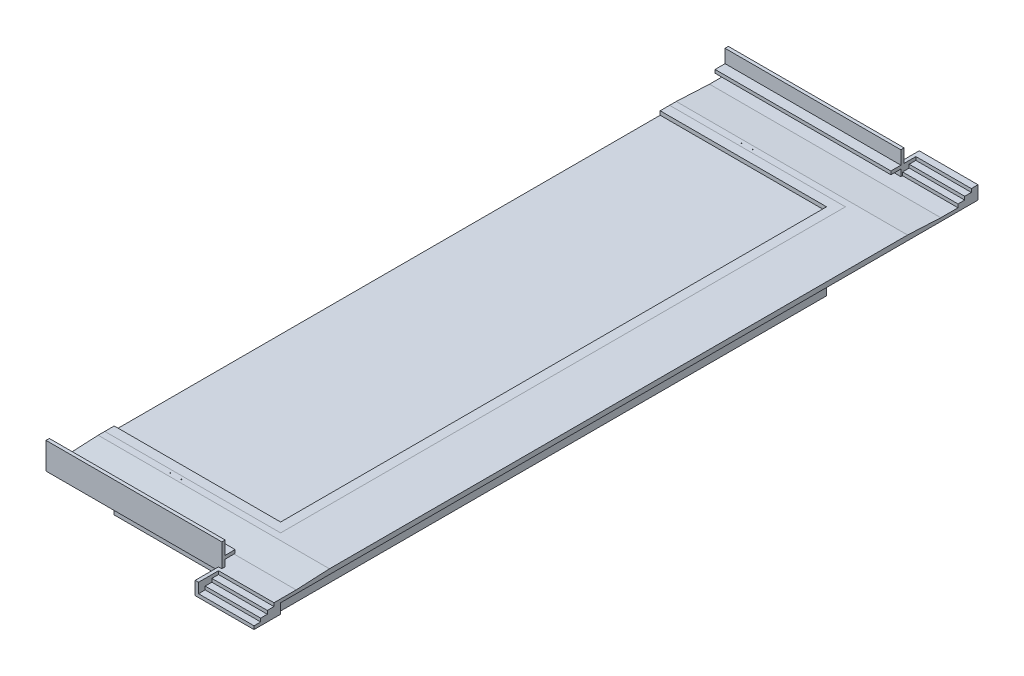
from build123d import *

# Parameters (mm, degrees)
SKETCH1_W                         = 7620
SKETCH1_H                         = 25000.0008
POOL_WATER_DEPTH                  = 3352.8
POOL_DECK_SUPPORT_DEPTH           = 101.6
POOL_DECK_SUPPORT_DEPTH_BACK      = 76.2
POOL_DECK_DEPTH                   = 152.4
SKETCH4_W                         = 8051.8
SKETCH4_H                         = 152.4
WALL_DEPTH                        = 1219.2
WALL_2_DEPTH                      = 1219.2
SKETCH7_W                         = 8051.8
SKETCH7_H                         = 152.4
NEAR_SIDE_BENCH_DEPTH             = 457.2
SKETCH8_W                         = 8051.8
SKETCH8_H                         = 152.4
FAR_SIDE_BENCH_DEPTH              = 457.2
STAIRS_DOWN_DEPTH                 = 2540
SLOPED_START                      = -8051.8
SLOPED_POOL_DECK_NEAR_SIDE_DEPTH  = 10591.8
SLOPED_POOL_DECK_FAR_SIDE_DEPTH   = 10591.8
SLOPED_POOL_DECK_LENGTH_DEPTH     = 25863.6008
DRAIN_CORRECTION_DEPTH            = 3455.4
STAIRS_UP_DEPTH                   = 2540
PERIMETER_DRAIN_DEPTH             = 228.6
SKETCH23_R                        = 3.175
FAR_SIDE_SWIM_LANE_EYELETS_DEPTH  = 152.4
SKETCH25_R                        = 3.175
NEAR_SIDE_SWIM_LANE_EYELETS_DEPTH = 152.4
SKETCH26_W                        = 838.2
SKETCH26_H                        = 609.6
FAR_SIDE_STAIRS_WALL_DEPTH        = 152.4
SKETCH27_W                        = 1066.8
SKETCH27_H                        = 609.6
NEAR_SIDE_STAIRS_WALL_DEPTH       = 152.4
SKETCH28_W                        = 101.6
SKETCH28_H                        = 127
FAR_SIDE_ELECTRICAL_BOX_DEPTH     = 76.2
SKETCH29_W                        = 25.4
SKETCH29_H                        = 25.4
FAR_SIDE_OUTLETS_DEPTH            = 6.35
FAR_SIDE_OUTLETS_2_DEPTH          = 6.35
SKETCH30_W                        = 101.6
SKETCH30_H                        = 127
NEAR_SIDE_ELECTRICAL_BOX_DEPTH    = 76.2
SKETCH31_W                        = 25.4
SKETCH31_H                        = 25.4
NEAR_SIDE_OUTLETS_DEPTH           = 6.35
NEAR_SIDE_OUTLETS_2_DEPTH         = 6.35
SKETCH32_R                        = 19.05
CUT_EXTRUDE4_DEPTH                = 152.4


with BuildPart() as part:
    # Sketch1 → Pool Water (new body)
    with BuildSketch(Plane(origin=(0, 0, 0), x_dir=(1, 0, 0), z_dir=(0, 1, 0))):
        with Locations((-3810, 12500.0004)):
            Rectangle(SKETCH1_W, SKETCH1_H)
    extrude(amount=-POOL_WATER_DEPTH)


with BuildPart() as body_2:
    # Sketch2 → Pool Deck Support (new body, two sides)
    with BuildSketch(Plane(origin=(0, 0, 0), x_dir=(1, 0, 0), z_dir=(0, 1, 0))) as pool_deck_support_sk:
        Polygon((-7620, 0), (-7620, -431.8), (431.8, -431.8), (431.8, 25431.8008), (-7620, 25431.8008), (-7620, 25000.0008), (0, 25000.0008), (0, 0), align=None)
    extrude(amount=POOL_DECK_SUPPORT_DEPTH)
    extrude(pool_deck_support_sk.sketch, amount=-POOL_DECK_SUPPORT_DEPTH_BACK)



with BuildPart() as body_3:
    # Sketch3 → Pool Deck (new body)
    with BuildSketch(Plane(origin=(0, 101.6, 0), x_dir=(1, 0, 0), z_dir=(0, 1, 0))):
        Polygon((-7620, -2971.8), (-7620, -431.8), (431.8, -431.8), (431.8, 25431.8008), (-7620, 25431.8008), (-7620, 27971.8008), (2971.8, 27971.8008), (2971.8, -2971.8), align=None)
    extrude(amount=-POOL_DECK_DEPTH)



with BuildPart() as body_4:
    # Sketch4 → Wall (new body)
    with BuildSketch(Plane(origin=(0, -50.8, 0), x_dir=(-1, 0, 0), z_dir=(0, -1, 0))):
        with Locations((3594.1, -3048)):
            Rectangle(SKETCH4_W, SKETCH4_H)
    extrude(amount=-WALL_DEPTH)

    # Sketch7 → Near Side Bench (add)
    with BuildSketch(Plane(origin=(0, 0, 2971.8), x_dir=(-1, 0, 0), z_dir=(0, 0, -1))):
        with Locations((3594.1, 482.6)):
            Rectangle(SKETCH7_W, SKETCH7_H)
    extrude(amount=NEAR_SIDE_BENCH_DEPTH)


with BuildPart() as body_5:
    # Sketch4 → Wall 2 (new body)
    with BuildSketch(Plane(origin=(0, -50.8, 0), x_dir=(-1, 0, 0), z_dir=(0, -1, 0))):
        with Locations((3594.1, 28048.0008)):
            Rectangle(SKETCH4_W, SKETCH4_H)
    extrude(amount=-WALL_2_DEPTH)

    # Sketch8 → Far Side Bench (add)
    with BuildSketch(Plane.XY.offset(-27971.8008)):
        with Locations((-3594.1, 482.6)):
            Rectangle(SKETCH8_W, SKETCH8_H)
    extrude(amount=FAR_SIDE_BENCH_DEPTH)


with BuildPart() as body_3_1:
    add(body_3.part)

    add(body_4.part)  # Stairs Down merges body 4
    # Sketch9 → Stairs Down (add)
    with BuildSketch(Plane(origin=(2971.8, 0, 0), x_dir=(0, 0, -1), z_dir=(1, 0, 0))):
        Polygon((-3276.6, -50.8), (-3581.4, -50.8), (-3581.4, -203.2), (-3886.2, -203.2), (-3886.2, -355.6), (-4191, -355.6), (-4191, -508), (-4160.29065508, -508), (-2971.8, -508), (-2971.8, -291.946336827), (-2971.8, 101.6), (-3276.6, 101.6), align=None)
    extrude(amount=-STAIRS_DOWN_DEPTH)


with BuildPart() as body_2_1:
    add(body_2.part)

    add(body_3_1.part)  # Sloped Pool Deck Near Side merges body 3
    # Sketch14 → Sloped Pool Deck Near Side (add)
    with BuildSketch(Plane(origin=(431.8, 0, 0), x_dir=(0, 0, -1), z_dir=(1, 0, 0)).offset(SLOPED_START)):
        Polygon((-431.8, 101.6), (-431.8, 177.8), (-736.6, 177.8), (-2260.6, 101.6), align=None)
    extrude(amount=SLOPED_POOL_DECK_NEAR_SIDE_DEPTH)

    # Sketch17 → Sloped Pool Deck Far Side (add)
    with BuildSketch(Plane.ZY.offset(7620)):
        Polygon((-25431.8008, 101.6), (-25431.8008, 177.8), (-25736.6008, 177.8), (-27260.6008, 101.6), align=None)
    extrude(amount=-SLOPED_POOL_DECK_FAR_SIDE_DEPTH)

    # Sketch15 → Sloped Pool Deck Length (add)
    with BuildSketch(Plane(origin=(0, 0, 431.8), x_dir=(-1, 0, 0), z_dir=(0, 0, -1))):
        Polygon((-431.8, 101.6), (-431.8, 177.8), (-1346.2, 177.8), (-2971.8, 177.8), (-2971.8, 101.6), (-2260.6, 101.6), (-1346.2, 101.6), align=None)
    extrude(amount=SLOPED_POOL_DECK_LENGTH_DEPTH)

    # Sketch19 → Drain Correction (cut, through all)
    with BuildSketch(Plane(origin=(0, 101.6, 0), x_dir=(1, 0, 0), z_dir=(0, 1, 0))):
        Polygon((-7620, 0), (-7620, -431.8), (431.8, -431.8), (431.8, 25431.8008), (-7620, 25431.8008), (-7620, 25000.0008), (0, 25000.0008), (0, 0), align=None)
    extrude(amount=-DRAIN_CORRECTION_DEPTH, mode=Mode.SUBTRACT)


    add(body_5.part)  # Stairs Up merges body 5
    # Sketch21 → Stairs Up (add)
    with BuildSketch(Plane(origin=(2971.8, 0, 0), x_dir=(0, 0, -1), z_dir=(1, 0, 0))):
        Polygon((28657.6008, 406.4), (28352.8008, 406.4), (28352.8008, 254), (28048.0008, 254), (28048.0008, 101.6), (27743.2008, 101.6), (27743.2008, -50.8), (28962.4008, -50.8), (28962.4008, 558.8), (28657.6008, 558.8), align=None)
    extrude(amount=-STAIRS_UP_DEPTH)

    # Sketch26 → Far Side Stairs Wall (add)
    with BuildSketch(Plane.ZY.offset(-431.8)):
        with Locations((-28543.3008, 254)):
            Rectangle(SKETCH26_W, SKETCH26_H)
    extrude(amount=FAR_SIDE_STAIRS_WALL_DEPTH)

    # Sketch27 → Near Side Stairs Wall (add)
    with BuildSketch(Plane.ZY.offset(-431.8)):
        with Locations((3657.6, -203.2)):
            Rectangle(SKETCH27_W, SKETCH27_H)
    extrude(amount=NEAR_SIDE_STAIRS_WALL_DEPTH)

    # Sketch32 → Cut-Extrude4 (cut)
    with BuildSketch(Plane(origin=(0, 177.8, 0), x_dir=(1, 0, 0), z_dir=(0, 1, 0))):
        with Locations((-4470.4, -584.2)):
            Circle(SKETCH32_R)
        with Locations((-3962.4, -584.2)):
            Circle(SKETCH32_R)
        with Locations((-4470.4, 25584.2008)):
            Circle(SKETCH32_R)
        with Locations((-3962.4, 25584.2008)):
            Circle(SKETCH32_R)
    extrude(amount=-CUT_EXTRUDE4_DEPTH, mode=Mode.SUBTRACT)


with BuildPart() as body_3_2:
    # Sketch20 → Perimeter Drain (new body)
    with BuildSketch(Plane(origin=(0, 177.8, 0), x_dir=(1, 0, 0), z_dir=(0, 1, 0))):
        Polygon((-7620, 0), (-7620, -431.8), (431.8, -431.8), (431.8, 25431.8008), (-7620, 25431.8008), (-7620, 25000.0008), (0, 25000.0008), (0, 0), align=None)
    extrude(amount=-PERIMETER_DRAIN_DEPTH)

    # Sketch23 → Far Side Swim Lane Eyelets (cut)
    with BuildSketch(Plane.XY.offset(-25000.0008)):
        with Locations((-5207, 25.4)):
            Circle(SKETCH23_R)
        with Locations((-787.4, 25.4)):
            Circle(SKETCH23_R)
    extrude(amount=-FAR_SIDE_SWIM_LANE_EYELETS_DEPTH, mode=Mode.SUBTRACT)

    # Sketch25 → Near Side Swim Lane Eyelets (cut)
    with BuildSketch(Plane(origin=(0, 0, 0), x_dir=(-1, 0, 0), z_dir=(0, 0, -1))):
        with Locations((787.4, 25.4)):
            Circle(SKETCH25_R)
        with Locations((5207, 25.4)):
            Circle(SKETCH25_R)
    extrude(amount=-NEAR_SIDE_SWIM_LANE_EYELETS_DEPTH, mode=Mode.SUBTRACT)


with BuildPart() as body_4_2:
    # Sketch28 → Far Side Electrical Box (new body)
    with BuildSketch(Plane.XY.offset(-27971.8008)):
        with Locations((-1346.2, 266.7)):
            Rectangle(SKETCH28_W, SKETCH28_H)
    extrude(amount=FAR_SIDE_ELECTRICAL_BOX_DEPTH)


with BuildPart() as body_5_2:
    # Sketch29 → Far Side Outlets (new body)
    with BuildSketch(Plane.XY.offset(-27895.6008)):
        with Locations((-1346.2, 292.1)):
            Rectangle(SKETCH29_W, SKETCH29_H)
    extrude(amount=FAR_SIDE_OUTLETS_DEPTH)


with BuildPart() as body_6:
    # Sketch29 → Far Side Outlets 2 (new body)
    with BuildSketch(Plane.XY.offset(-27895.6008)):
        with Locations((-1346.2, 241.3)):
            Rectangle(SKETCH29_W, SKETCH29_H)
    extrude(amount=FAR_SIDE_OUTLETS_2_DEPTH)


with BuildPart() as body_7:
    # Sketch30 → Near Side Electrical Box (new body)
    with BuildSketch(Plane(origin=(0, 0, 2971.8), x_dir=(-1, 0, 0), z_dir=(0, 0, -1))):
        with Locations((2159, 266.7)):
            Rectangle(SKETCH30_W, SKETCH30_H)
    extrude(amount=NEAR_SIDE_ELECTRICAL_BOX_DEPTH)


with BuildPart() as body_8:
    # Sketch31 → Near Side Outlets (new body)
    with BuildSketch(Plane(origin=(0, 0, 2895.6), x_dir=(-1, 0, 0), z_dir=(0, 0, -1))):
        with Locations((2159, 292.1)):
            Rectangle(SKETCH31_W, SKETCH31_H)
    extrude(amount=NEAR_SIDE_OUTLETS_DEPTH)


with BuildPart() as body_9:
    # Sketch31 → Near Side Outlets 2 (new body)
    with BuildSketch(Plane(origin=(0, 0, 2895.6), x_dir=(-1, 0, 0), z_dir=(0, 0, -1))):
        with Locations((2159, 241.3)):
            Rectangle(SKETCH31_W, SKETCH31_H)
    extrude(amount=NEAR_SIDE_OUTLETS_2_DEPTH)


solid = Compound([part.part, body_2_1.part, body_3_2.part, body_4_2.part, body_5_2.part, body_6.part, body_7.part, body_8.part, body_9.part])
